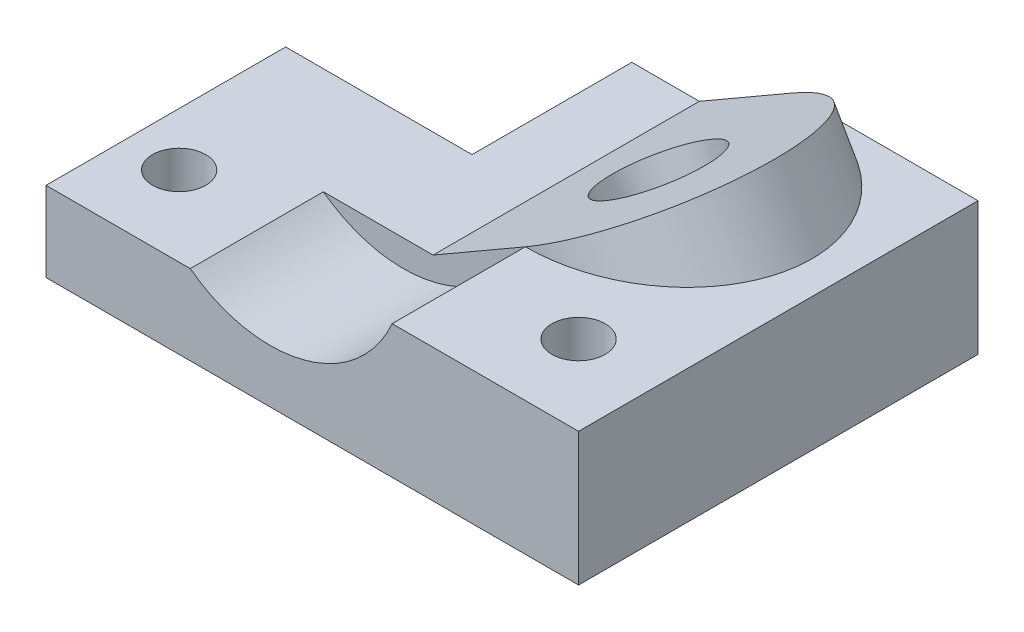
from build123d import *

# Parameters (mm, degrees)
IZIM1_W                     = 35
IZIM1_H                     = 75
Y_KSEKLIK_EKSTR_ZYON1_DEPTH = 25
Y_KSEKLIK_EKSTR_ZYON2_DEPTH = 15
KES_EKSTR_ZYON1_DEPTH       = 25
Y_KSEKLIK_EKSTR_ZYON3_DEPTH = 25
IZIM3_R                     = 5
KES_EKSTR_ZYON2_DEPTH       = 25
IZIM4_R                     = 5
KES_EKSTR_ZYON3_DEPTH       = 128.47548784
Y_KSEKLIK_EKSTR_ZYON4_DEPTH = 50
Y_KSEKLIK_EKSTR_ZYON5_REACH = 117.077
IZIM7_R                     = 10
KES_EKSTR_ZYON4_DEPTH       = 116.076968672


with BuildPart() as part:
    # Çizim1 → Yükseklik-Ekstrüzyon1 (new body)
    with BuildSketch(Plane(origin=(0, 0, 0), x_dir=(1, 0, 0), z_dir=(0, 1, 0))):
        with Locations((-17.5, 37.5)):
            Rectangle(IZIM1_W, IZIM1_H)
    extrude(amount=Y_KSEKLIK_EKSTR_ZYON1_DEPTH)

    # Çizim1<4> → Yükseklik-Ekstrüzyon2 (add)
    with BuildSketch(Plane(origin=(0, 0, 0), x_dir=(1, 0, 0), z_dir=(0, 1, 0))):
        Polygon((-35, 75), (-65, 75), (-65, 45), (-100, 45), (-100, 0), (-35, 0), align=None)
    extrude(amount=Y_KSEKLIK_EKSTR_ZYON2_DEPTH)

    # Çizim2 → Kes-Ekstrüzyon1 (cut)
    with BuildSketch(Plane.XY):
        with BuildLine():
            Line((-42.912878475, 15), (-72.912878475, 15))
            ThreePointArc((-72.912878475, 15), (-57.912878475, 10), (-42.912878475, 15))
        make_face()
    extrude(amount=-KES_EKSTR_ZYON1_DEPTH, mode=Mode.SUBTRACT)

    # Çizim2<3> → Yükseklik-Ekstrüzyon3 (add)
    with BuildSketch(Plane.XY):
        with BuildLine():
            ThreePointArc((-35, 25), (-38.30811914, 19.486992186), (-42.912878475, 15))
            Line((-42.912878475, 15), (-35, 15))
            Line((-35, 15), (-35, 25))
        make_face()
    extrude(amount=-Y_KSEKLIK_EKSTR_ZYON3_DEPTH)

    # Çizim3 → Kes-Ekstrüzyon2 (cut)
    with BuildSketch(Plane(origin=(0, 15, 0), x_dir=(1, 0, 0), z_dir=(0, 1, 0))):
        with Locations((-90, 15)):
            Circle(IZIM3_R)
    extrude(amount=-KES_EKSTR_ZYON2_DEPTH, mode=Mode.SUBTRACT)

    # Çizim4 → Kes-Ekstrüzyon3 (cut, through all)
    with BuildSketch(Plane(origin=(0, 25, 0), x_dir=(1, 0, 0), z_dir=(0, 1, 0))):
        with Locations((-15, 15)):
            Circle(IZIM4_R)
    extrude(amount=-KES_EKSTR_ZYON3_DEPTH, mode=Mode.SUBTRACT)

    # Çizim5 → Yükseklik-Ekstrüzyon4 (add)
    with BuildSketch(Plane.XY.offset(-75)):
        Polygon((-35, 25), (-52.320508076, 15), (-35, 15), align=None)
    extrude(amount=Y_KSEKLIK_EKSTR_ZYON4_DEPTH)

    # Yükseklik-Ekstrüzyon5: up to this face of the body (flat: up to its plane)
    y_kseklik_ekstr_zyon5_end = Plane(part.part.faces().sort_by_distance((-17.577106857, 25, -38.193961712))[0])
    # Çizim6 → Yükseklik-Ekstrüzyon5 (add, up to the picked face)
    with BuildSketch(Plane(origin=(-19.575317547, 33.905444566, 0), x_dir=(0.8660254037844379, 0.5000000000000013, 0), z_dir=(-0.5000000000000013, 0.8660254037844379, 0)), mode=Mode.PRIVATE) as y_kseklik_ekstr_zyon5_sk1:
        with BuildLine():
            Line((-17.810889132, 25), (-17.810889132, 75))
            ThreePointArc((-17.810889132, 75), (7.189110868, 50), (-17.810889132, 25))
        make_face()
    y_kseklik_ekstr_zyon5_tool1 = split(extrude(y_kseklik_ekstr_zyon5_sk1.sketch, amount=-Y_KSEKLIK_EKSTR_ZYON5_REACH, mode=Mode.PRIVATE), bisect_by=y_kseklik_ekstr_zyon5_end, keep=Keep.BOTH, mode=Mode.PRIVATE)
    add(y_kseklik_ekstr_zyon5_tool1.solids().sort_by(Axis((-25.811185, 30.305165, -50), (0.5000000000000013, -0.8660254037844379, 0)))[0])

    # Çizim7 → Kes-Ekstrüzyon4 (cut, through all)
    with BuildSketch(Plane(origin=(-19.575317547, 33.905444566, 0), x_dir=(0.8660254037844379, 0.5000000000000013, 0), z_dir=(-0.5000000000000013, 0.8660254037844379, 0))):
        with Locations((-17.810889132, 50)):
            Circle(IZIM7_R)
    extrude(amount=-KES_EKSTR_ZYON4_DEPTH, mode=Mode.SUBTRACT)


solid = part.part
